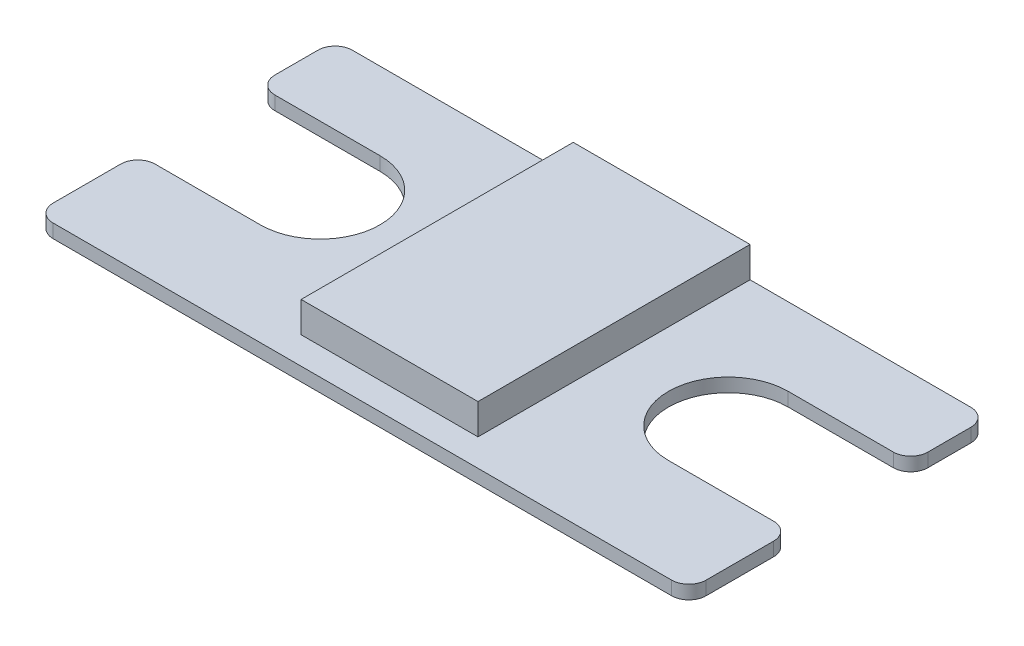
from build123d import *

# Parameters (mm, degrees)
BOSS_EXTRUDE1_DEPTH = 1
FILLET1_R           = 1.27
SKETCH2_W           = 13
SKETCH2_H           = 20
BOSS_EXTRUDE2_DEPTH = 2.25


with BuildPart() as part:
    # Sketch1 → Boss-Extrude1 (new body)
    with BuildSketch(Plane(origin=(0, 0, 0), x_dir=(1, 0, 0), z_dir=(0, 1, 0))):
        with BuildLine():
            Line((0, 0), (0, 7.5))
            Line((0, 7.5), (9, 7.5))
            ThreePointArc((9, 7.5), (13.4, 11.9), (9, 16.3))
            Line((9, 16.3), (0, 16.3))
            Line((0, 16.3), (0, 22))
            Line((0, 22), (48, 22))
            Line((48, 22), (48, 16.3))
            Line((48, 16.3), (39, 16.3))
            ThreePointArc((39, 16.3), (34.6, 11.9), (39, 7.5))
            Line((39, 7.5), (48, 7.5))
            Line((48, 7.5), (48, 0))
            Line((48, 0), (0, 0))
        make_face()
    extrude(amount=BOSS_EXTRUDE1_DEPTH)

    # Fillet1
    fillet1_edges = [part.edges().sort_by_distance(p)[0] for p in [
        (0, 0.5, 0),
        (0, 0.5, -7.5),
        (0, 0.5, -16.3),
        (0, 0.5, -22),
        (48, 0.5, -22),
        (48, 0.5, -16.3),
        (48, 0.5, -7.5),
        (48, 0.5, 0),
    ]]
    fillet(fillet1_edges, radius=FILLET1_R)

    # Sketch2 → Boss-Extrude2 (add)
    with BuildSketch(Plane(origin=(0, 1, 0), x_dir=(1, 0, 0), z_dir=(0, 1, 0))):
        with Locations((24, 12)):
            Rectangle(SKETCH2_W, SKETCH2_H)
    extrude(amount=BOSS_EXTRUDE2_DEPTH)


solid = part.part
